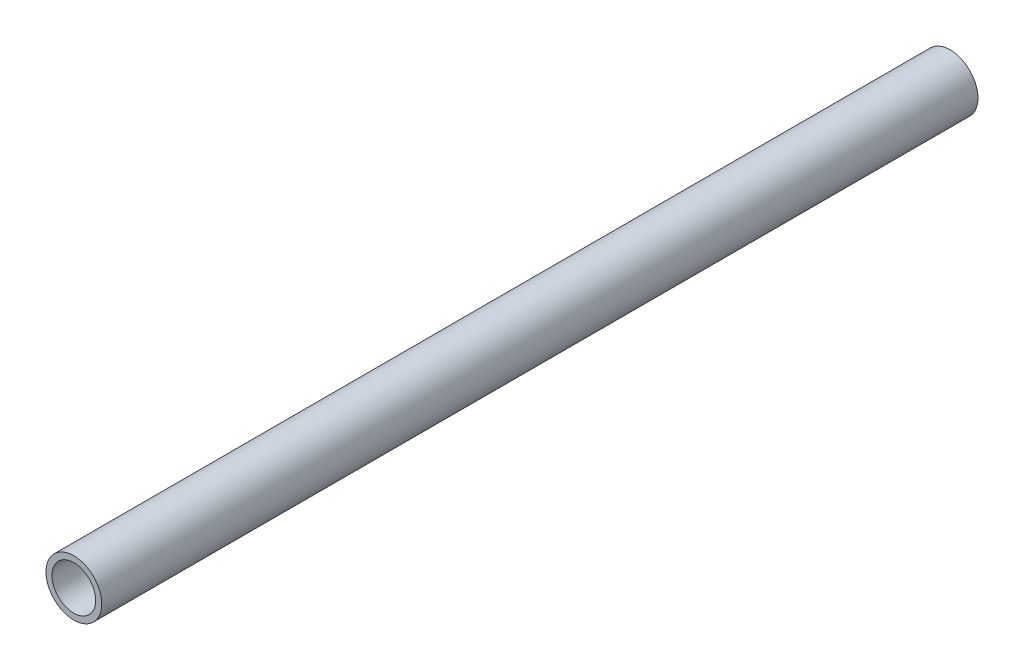
from build123d import *

# Parameters (mm, degrees)
SKETCH1_R           = 13.335
SKETCH1_R_2         = 10.4648
BOSS_EXTRUDE1_DEPTH = 419.1


with BuildPart() as part:
    # Sketch1 → Boss-Extrude1 (new body)
    with BuildSketch(Plane.XY):
        Circle(SKETCH1_R)
        Circle(SKETCH1_R_2, mode=Mode.SUBTRACT)
    extrude(amount=BOSS_EXTRUDE1_DEPTH)


solid = part.part
